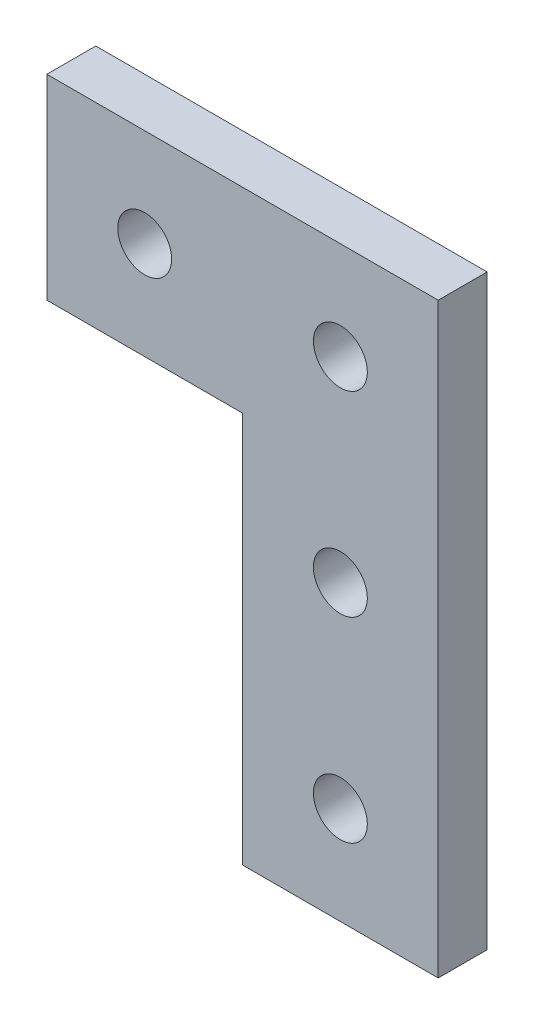
from build123d import *

# Parameters (mm, degrees)
BOSS_EXTRUDE1_DEPTH = 6.35
SKETCH2_R           = 3.5
CUT_EXTRUDE1_DEPTH  = 7.35
SKETCH3_W           = 14.231578179
SKETCH3_H           = 34.511577086
CUT_EXTRUDE2_DEPTH  = 25


with BuildPart() as part:
    # Sketch1 → Boss-Extrude1 (new body)
    with BuildSketch(Plane.XY):
        Polygon((12.7, 0), (-12.7, 0), (-12.7, 50.8), (-63.1, 50.8), (-63.1, 76.2), (12.7, 76.2), (12.7, 50.8), align=None)
    extrude(amount=BOSS_EXTRUDE1_DEPTH)

    # Sketch2 → Cut-Extrude1 (cut, through all)
    with BuildSketch(Plane.XY.offset(6.35)):
        with Locations((0, 63.5)):
            Circle(SKETCH2_R)
        with Locations((-25.4, 63.5)):
            Circle(SKETCH2_R)
        with Locations((0, 38.1)):
            Circle(SKETCH2_R)
        with Locations((0, 12.7)):
            Circle(SKETCH2_R)
        with Locations((-50.8, 63.5)):
            Circle(SKETCH2_R)
    extrude(amount=-CUT_EXTRUDE1_DEPTH, mode=Mode.SUBTRACT)

    # Sketch3 → Cut-Extrude2 (cut)
    with BuildSketch(Plane.ZY.offset(63.1)):
        with Locations((3.571370897, 64.988127963)):
            Rectangle(SKETCH3_W, SKETCH3_H)
    extrude(amount=-CUT_EXTRUDE2_DEPTH, mode=Mode.SUBTRACT)


solid = part.part
